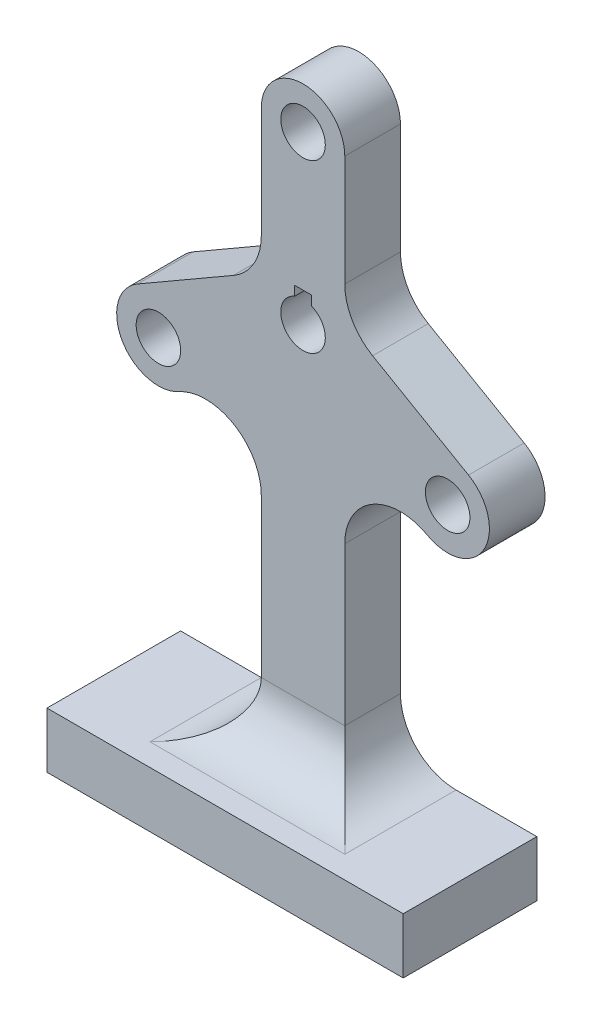
from build123d import *

# Parameters (mm, degrees)
SKETCH1_W           = 15.000000116
SKETCH1_H           = 37.5
BOSS_EXTRUDE1_DEPTH = 10
CIRPATTERN1_COUNT   = 3
SKETCH2_R           = 4
CUT_EXTRUDE1_DEPTH  = 11
SKETCH3_W           = 15
SKETCH3_H           = 72.846718993
BOSS_EXTRUDE2_DEPTH = 10
BOSS_EXTRUDE3_START = -10
SKETCH4_W           = 64
SKETCH4_H           = 10
BOSS_EXTRUDE3_DEPTH = 24
FILLET2_R           = 7.5
FILLET3_R           = 7.5
FILLET4_R           = 7.5
FILLET5_R           = 10
FILLET6_R           = 10
SKETCH5_W           = 60.8
SKETCH5_H           = 20.8
CUT_EXTRUDE2_DEPTH  = 8
BOSS_EXTRUDE4_DEPTH = 8
LPATTERN1_COUNT     = 7
LPATTERN1_PITCH     = 8
SKETCH6_3_W         = 0.8
SKETCH6_3_H         = 0.4
SKETCH6_3_W_2       = 0.4
SKETCH6_3_H_2       = 0.8
BOSS_EXTRUDE5_DEPTH = 8


with BuildPart() as part:
    # Sketch1 → Boss-Extrude1 (new body)
    with BuildSketch(Plane.XY):
        with Locations((0, 18.75)):
            Rectangle(SKETCH1_W, SKETCH1_H)
    boss_extrude1 = extrude(amount=BOSS_EXTRUDE1_DEPTH)

    # CirPattern1: Boss-Extrude1 ×3 about axis
    cirpattern1_axis = Axis((0, 0, 0), (0, 0, 1))
    for i in range(1, CIRPATTERN1_COUNT):
        add(boss_extrude1.rotate(cirpattern1_axis, i * 360 / CIRPATTERN1_COUNT))

    # Sketch2 → Cut-Extrude1 (cut, through all)
    with BuildSketch(Plane.XY.offset(10)):
        with BuildLine():
            Line((1.5, 5.4), (-1.5, 5.4))
            Line((-1.5, 5.4), (-1.5, 3.708099244))
            ThreePointArc((-1.5, 3.708099244), (0, -4), (1.5, 3.708099244))
            Line((1.5, 3.708099244), (1.5, 5.4))
        make_face()
        with Locations((-25.980762114, -15)):
            Circle(SKETCH2_R)
        with Locations((0, 30)):
            Circle(SKETCH2_R)
        with Locations((25.980762114, -15)):
            Circle(SKETCH2_R)
    extrude(amount=-CUT_EXTRUDE1_DEPTH, mode=Mode.SUBTRACT)

    # Sketch3 → Boss-Extrude2 (add)
    with BuildSketch(Plane(origin=(0, 0, 0), x_dir=(-1, 0, 0), z_dir=(0, 0, -1))):
        with Locations((0, -42.194852455)):
            Rectangle(SKETCH3_W, SKETCH3_H)
    extrude(amount=-BOSS_EXTRUDE2_DEPTH)

    # Sketch4 → Boss-Extrude3 (add)
    with BuildSketch(Plane.XY.offset(10).offset(BOSS_EXTRUDE3_START)):
        with Locations((0, -73.618211951)):
            Rectangle(SKETCH4_W, SKETCH4_H)
    extrude(amount=BOSS_EXTRUDE3_DEPTH)

    # Fillet2
    fillet2_edges = [part.edges().sort_by_distance(p)[0] for p in [
        (-7.500000058, 37.5, 5),
        (7.500000058, 37.5, 5),
    ]]
    fillet(fillet2_edges, radius=FILLET2_R)

    # Fillet3
    fillet3_edges = [part.edges().sort_by_distance(p)[0] for p in [
        (36.225952671, -12.254809421, 5),
        (28.725952613, -25.245190579, 5),
    ]]
    fillet(fillet3_edges, radius=FILLET3_R)

    # Fillet4
    fillet4_edges = [part.edges().sort_by_distance(p)[0] for p in [
        (-28.725952613, -25.245190579, 5),
        (-36.225952671, -12.254809421, 5),
    ]]
    fillet(fillet4_edges, radius=FILLET4_R)

    # Fillet5
    fillet5_edges = [part.edges().sort_by_distance(p)[0] for p in [
        (-7.500000058, 4.330127052, 5),
        (7.500000058, 4.330127052, 5),
        (7.5, -12.990381124, 5),
        (-7.5, -12.990381124, 5),
    ]]
    fillet(fillet5_edges, radius=FILLET5_R)

    # Fillet6
    fillet6_edges = [part.edges().sort_by_distance(p)[0] for p in [
        (7.5, -68.618211951, 5),
        (0, -68.618211951, 10),
        (-7.5, -68.618211951, 5),
    ]]
    fillet(fillet6_edges, radius=FILLET6_R)

    # Sketch5 → Cut-Extrude2 (cut)
    with BuildSketch(Plane.XZ.offset(78.618211951)):
        with Locations((0, 12)):
            Rectangle(SKETCH5_W, SKETCH5_H)
    extrude(amount=-CUT_EXTRUDE2_DEPTH, mode=Mode.SUBTRACT)

    # Sketch6 → Boss-Extrude4 (add)
    with BuildSketch(Plane.XZ.offset(70.618211951)):
        with BuildLine():
            ThreePointArc((23.6, 11.231336566), (20.744, 8), (23.6, 4.768663434))
            Line((23.6, 4.768663434), (23.6, 1.6))
            Line((23.6, 1.6), (24.4, 1.6))
            Line((24.4, 1.6), (24.4, 4.768663434))
            ThreePointArc((24.4, 4.768663434), (27.256, 8), (24.4, 11.231336566))
            Line((24.4, 11.231336566), (24.4, 12.768663434))
            ThreePointArc((24.4, 12.768663434), (27.256, 16), (24.4, 19.231336566))
            Line((24.4, 19.231336566), (24.4, 22.4))
            Line((24.4, 22.4), (23.6, 22.4))
            Line((23.6, 22.4), (23.6, 19.231336566))
            ThreePointArc((23.6, 19.231336566), (20.744, 16), (23.6, 12.768663434))
            Line((23.6, 12.768663434), (23.6, 11.231336566))
        make_face()
        with BuildLine():
            ThreePointArc((25.148817363, 5.892817363), (24, 5.6), (22.851182637, 5.892817363))
            Line((22.851182637, 5.892817363), (21.892817363, 6.851182637))
            ThreePointArc((21.892817363, 6.851182637), (21.6, 8), (21.892817363, 9.148817363))
            Line((21.892817363, 9.148817363), (22.851182637, 10.107182637))
            ThreePointArc((22.851182637, 10.107182637), (24, 10.4), (25.148817363, 10.107182637))
            Line((25.148817363, 10.107182637), (26.107182637, 9.148817363))
            ThreePointArc((26.107182637, 9.148817363), (26.4, 8), (26.107182637, 6.851182637))
            Line((26.107182637, 6.851182637), (25.148817363, 5.892817363))
        make_face(mode=Mode.SUBTRACT)
        with BuildLine():
            ThreePointArc((26.107182637, 17.148817363), (26.4, 16), (26.107182637, 14.851182637))
            Line((26.107182637, 14.851182637), (25.148817363, 13.892817363))
            ThreePointArc((25.148817363, 13.892817363), (24, 13.6), (22.851182637, 13.892817363))
            Line((22.851182637, 13.892817363), (21.892817363, 14.851182637))
            ThreePointArc((21.892817363, 14.851182637), (21.6, 16), (21.892817363, 17.148817363))
            Line((21.892817363, 17.148817363), (22.851182637, 18.107182637))
            ThreePointArc((22.851182637, 18.107182637), (24, 18.4), (25.148817363, 18.107182637))
            Line((25.148817363, 18.107182637), (26.107182637, 17.148817363))
        make_face(mode=Mode.SUBTRACT)
    boss_extrude4 = extrude(amount=BOSS_EXTRUDE4_DEPTH)

    # LPattern1: Boss-Extrude4 ×7
    with Locations(*[(-i * LPATTERN1_PITCH, 0, 0) for i in range(1, LPATTERN1_COUNT)]):
        add(boss_extrude4)

    # Sketch6_3 → Boss-Extrude5 (add)
    with BuildSketch(Plane.XZ.offset(70.618211951)):
        with Locations((20, 1.8)):
            Rectangle(SKETCH6_3_W, SKETCH6_3_H)
        with Locations((12, 1.8)):
            Rectangle(SKETCH6_3_W, SKETCH6_3_H)
        with Locations((4, 1.8)):
            Rectangle(SKETCH6_3_W, SKETCH6_3_H)
        with Locations((-4, 1.8)):
            Rectangle(SKETCH6_3_W, SKETCH6_3_H)
        with Locations((-12, 1.8)):
            Rectangle(SKETCH6_3_W, SKETCH6_3_H)
        with Locations((-28, 1.8)):
            Rectangle(SKETCH6_3_W, SKETCH6_3_H)
        with Locations((-30.2, 4)):
            Rectangle(SKETCH6_3_W_2, SKETCH6_3_H_2)
        with Locations((-30.2, 12)):
            Rectangle(SKETCH6_3_W_2, SKETCH6_3_H_2)
        with Locations((-30.2, 20)):
            Rectangle(SKETCH6_3_W_2, SKETCH6_3_H_2)
        with Locations((-12, 22.2)):
            Rectangle(SKETCH6_3_W, SKETCH6_3_H)
        with Locations((4, 22.2)):
            Rectangle(SKETCH6_3_W, SKETCH6_3_H)
        with Locations((12, 22.2)):
            Rectangle(SKETCH6_3_W, SKETCH6_3_H)
        with Locations((20, 22.2)):
            Rectangle(SKETCH6_3_W, SKETCH6_3_H)
        with Locations((28, 22.2)):
            Rectangle(SKETCH6_3_W, SKETCH6_3_H)
        with Locations((30.2, 12)):
            Rectangle(SKETCH6_3_W_2, SKETCH6_3_H_2)
        with Locations((28, 1.8)):
            Rectangle(SKETCH6_3_W, SKETCH6_3_H)
        with Locations((30.2, 4)):
            Rectangle(SKETCH6_3_W_2, SKETCH6_3_H_2)
        with Locations((-20, 1.8)):
            Rectangle(SKETCH6_3_W, SKETCH6_3_H)
        with Locations((-28, 22.2)):
            Rectangle(SKETCH6_3_W, SKETCH6_3_H)
        with Locations((-20, 22.2)):
            Rectangle(SKETCH6_3_W, SKETCH6_3_H)
        with Locations((-4, 22.2)):
            Rectangle(SKETCH6_3_W, SKETCH6_3_H)
        with Locations((30.2, 20)):
            Rectangle(SKETCH6_3_W_2, SKETCH6_3_H_2)
    extrude(amount=BOSS_EXTRUDE5_DEPTH)


solid = part.part
